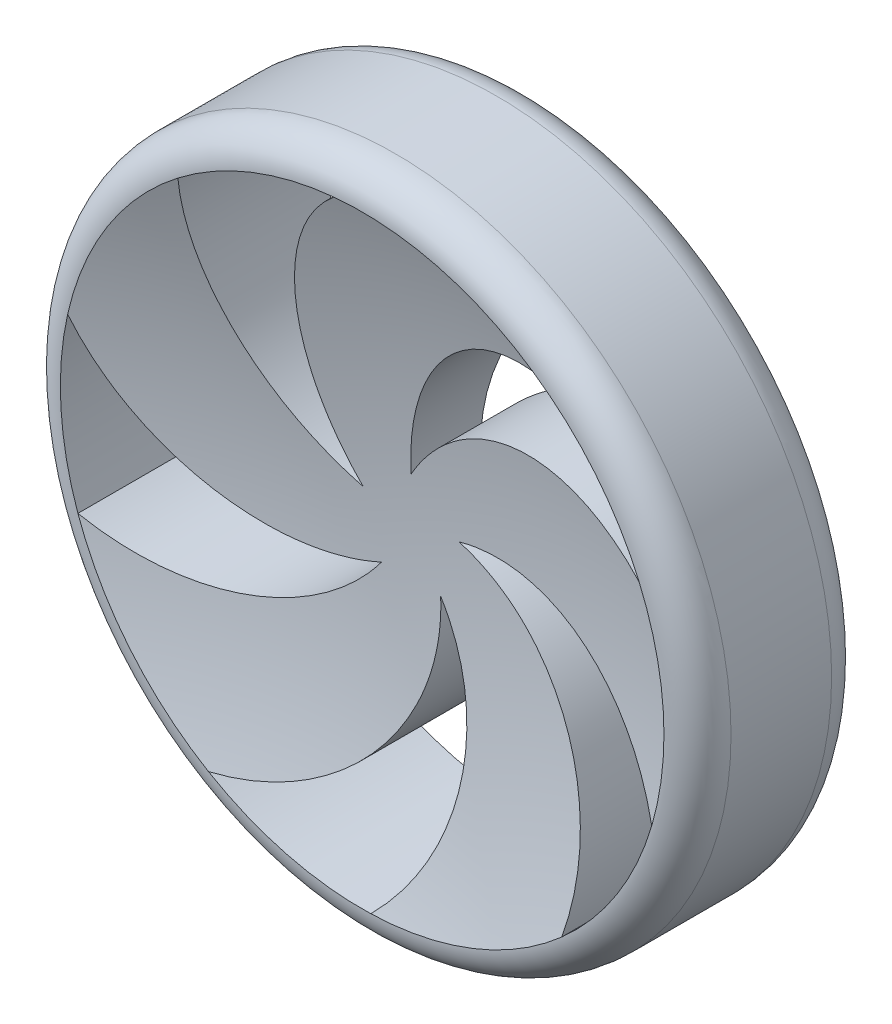
from build123d import *

# Parameters (mm, degrees)
SKETCH1_R           = 100
BOSS_EXTRUDE1_DEPTH = 50
FILLET1_R           = 10
CUT_EXTRUDE1_DEPTH  = 51
CIRPATTERN1_COUNT   = 5


with BuildPart() as part:
    # Sketch1 → Boss-Extrude1 (new body)
    with BuildSketch(Plane.XY):
        Circle(SKETCH1_R)
    extrude(amount=BOSS_EXTRUDE1_DEPTH)

    # Fillet1
    fillet1_edges = [part.edges().sort_by_distance(p)[0] for p in [
        (-100, 0, 0),
        (-100, 0, 50),
    ]]
    fillet(fillet1_edges, radius=FILLET1_R)

    # Sketch2 → Cut-Extrude1 (cut, through all)
    with BuildSketch(Plane.XY.offset(50)):
        with BuildLine():
            ThreePointArc((50.802293201, 74.290827196), (14.437611959, 54.039323714), (0, 15))
            ThreePointArc((0, 15), (36.99293279, 42.556106586), (82.610843349, 35.713422703))
            ThreePointArc((82.610843349, 35.713422703), (69.439328089, 57.255390267), (50.802293201, 74.290827196))
        make_face()
    cut_extrude1 = extrude(amount=-CUT_EXTRUDE1_DEPTH, mode=Mode.SUBTRACT)

    # CirPattern1: Cut-Extrude1 ×5 about axis
    cirpattern1_axis = Axis((0, 0, 0), (0, 0, 1))
    for i in range(1, CIRPATTERN1_COUNT):
        add(cut_extrude1.rotate(cirpattern1_axis, i * 360 / CIRPATTERN1_COUNT), mode=Mode.SUBTRACT)

    # Sketch3 → Cut-Revolve1 (revolve, cut)
    with BuildSketch(Plane(origin=(0, 0, 0), x_dir=(1, 0, 0), z_dir=(0, 1, 0))):
        with BuildLine():
            Line((0, 0), (-90, 0))
            ThreePointArc((-90, 0), (-45.620718977, -11.224313863), (0, -15))
            Line((0, -15), (0, 0))
        make_face()
        with BuildLine():
            Line((0, -50), (-90, -50))
            ThreePointArc((-90, -50), (-45.620718977, -38.775686137), (0, -35))
            Line((0, -35), (0, -50))
        make_face()
    revolve(axis=Axis((0, 0, 50), (0, 0, -1)), mode=Mode.SUBTRACT)


solid = part.part
